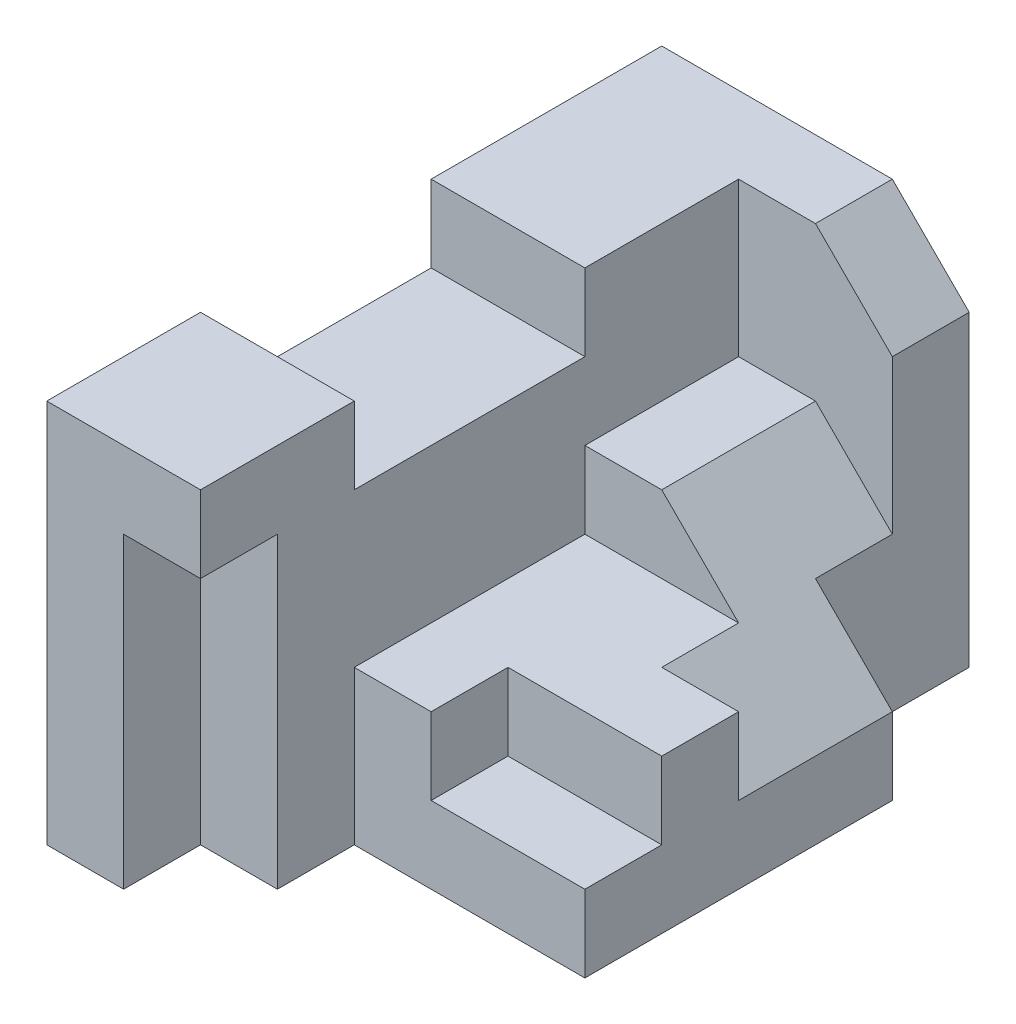
from build123d import *

# Parameters (mm, degrees)
SKETCH1_W           = 5
SKETCH1_H           = 5
BOSS_EXTRUDE1_DEPTH = 8
SKETCH2_W           = 2
SKETCH2_H           = 3
CUT_EXTRUDE1_DEPTH  = 1
SKETCH4_W           = 1
SKETCH4_H           = 4
CUT_EXTRUDE4_DEPTH  = 4
SKETCH5_W           = 1
SKETCH5_H           = 2
CUT_EXTRUDE5_DEPTH  = 3
CUT_EXTRUDE6_DEPTH  = 3
SKETCH7_W           = 2
SKETCH7_H           = 1
CUT_EXTRUDE7_DEPTH  = 1
CUT_EXTRUDE8_DEPTH  = 2
CUT_EXTRUDE9_DEPTH  = 2
CUT_EXTRUDE10_DEPTH = 2


with BuildPart() as part:
    # Sketch1 → Boss-Extrude1 (new body)
    with BuildSketch(Plane.XY):
        Rectangle(SKETCH1_W, SKETCH1_H)
    extrude(amount=BOSS_EXTRUDE1_DEPTH)

    # Sketch2 → Cut-Extrude1 (cut)
    with BuildSketch(Plane(origin=(0, 2.5, 0), x_dir=(1, 0, 0), z_dir=(0, 1, 0))):
        with Locations((-1.5, -4.5)):
            Rectangle(SKETCH2_W, SKETCH2_H)
    extrude(amount=-CUT_EXTRUDE1_DEPTH, mode=Mode.SUBTRACT)

    # Sketch4 → Cut-Extrude4 (cut)
    with BuildSketch(Plane(origin=(2.5, 0, 0), x_dir=(0, 0, -1), z_dir=(1, 0, 0))):
        with Locations((-7.5, -0.5)):
            Rectangle(SKETCH4_W, SKETCH4_H)
    extrude(amount=-CUT_EXTRUDE4_DEPTH, mode=Mode.SUBTRACT)

    # Sketch5 → Cut-Extrude5 (cut)
    with BuildSketch(Plane(origin=(2.5, 0, 0), x_dir=(0, 0, -1), z_dir=(1, 0, 0))):
        with Locations((-6.5, -1.5)):
            Rectangle(SKETCH5_W, SKETCH5_H)
    extrude(amount=-CUT_EXTRUDE5_DEPTH, mode=Mode.SUBTRACT)

    # Sketch6 → Cut-Extrude6 (cut)
    with BuildSketch(Plane(origin=(2.5, 0, 0), x_dir=(0, 0, -1), z_dir=(1, 0, 0))):
        Polygon((-8, 1.5), (-8, 2.5), (-1, 2.5), (-1, 0.5), (-3, 0.5), (-3, -0.5), (-6, -0.5), (-7, -0.5), (-7, 1.5), align=None)
    extrude(amount=-CUT_EXTRUDE6_DEPTH, mode=Mode.SUBTRACT)

    # Sketch7 → Cut-Extrude7 (cut)
    with BuildSketch(Plane.XY.offset(6)):
        with Locations((1.5, -1)):
            Rectangle(SKETCH7_W, SKETCH7_H)
    extrude(amount=-CUT_EXTRUDE7_DEPTH, mode=Mode.SUBTRACT)

    # Sketch8 → Cut-Extrude8 (cut)
    with BuildSketch(Plane(origin=(0, 0, 0), x_dir=(-1, 0, 0), z_dir=(0, 0, -1))):
        Polygon((-0.5, 2.5), (-1.5, 1.5), (-1.5, -2.5), (-2.5, -2.5), (-2.5, 2.5), align=None)
    extrude(amount=-CUT_EXTRUDE8_DEPTH, mode=Mode.SUBTRACT)

    # Sketch9 → Cut-Extrude9 (cut)
    with BuildSketch(Plane.XY.offset(3)):
        Polygon((0.5, 0.5), (1.5, -0.5), (2.5, -0.5), (2.5, 0.5), align=None)
    extrude(amount=-CUT_EXTRUDE9_DEPTH, mode=Mode.SUBTRACT)

    # Sketch10 → Cut-Extrude10 (cut)
    with BuildSketch(Plane(origin=(0, 0, 2), x_dir=(-1, 0, 0), z_dir=(0, 0, -1))):
        Polygon((-1.5, -0.5), (-2.5, -1.5), (-2.5, -0.5), align=None)
    extrude(amount=-CUT_EXTRUDE10_DEPTH, mode=Mode.SUBTRACT)


solid = part.part
